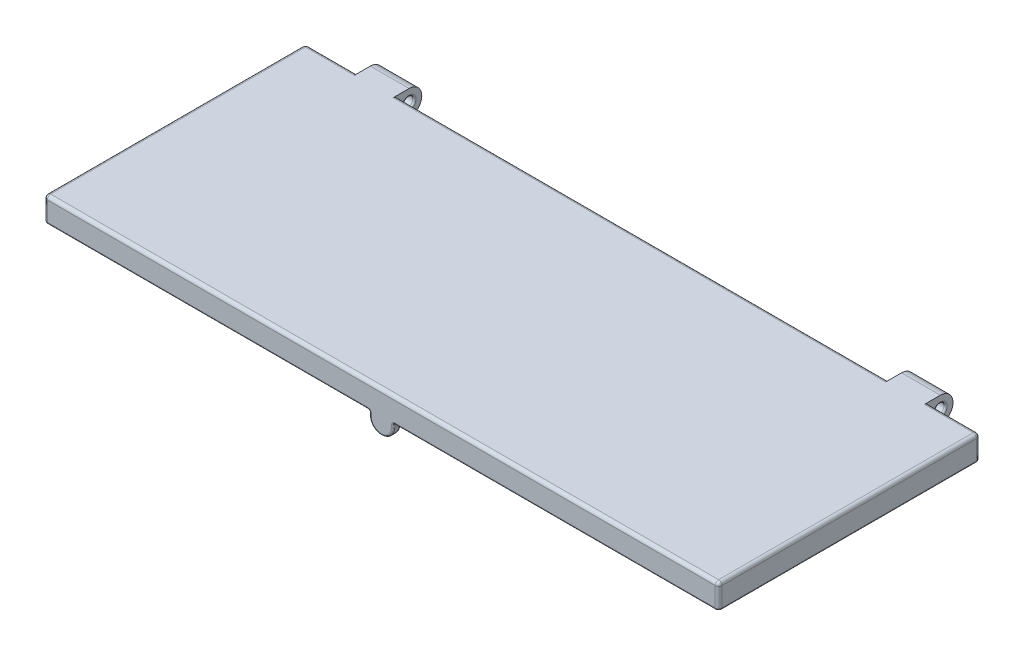
from build123d import *

# Parameters (mm, degrees)
SKETCH_1_W          = 160
SKETCH_1_H          = 62
EXTRUDE_1_DEPTH     = 4
SKETCH_2_R          = 3
SKETCH_2_R_2        = 1.25
EXTRUDE_2_DEPTH     = 9.2
EXTRUDE_3_DEPTH     = 1.8
EXTRUDE_4_DEPTH     = 1.8
SKETCH_5_R          = 0.6
CUT_EXTRUDE_1_DEPTH = 0.4
FILLET_1_R          = 0.8
FILLET_2_R          = 0.4
FILLET_3_R          = 0.1


with BuildPart() as part:
    # 草图1 → 凸台-拉伸1 (new body)
    with BuildSketch(Plane(origin=(0, 0, 0), x_dir=(1, 0, 0), z_dir=(0, 1, 0))):
        with Locations((80, 31)):
            Rectangle(SKETCH_1_W, SKETCH_1_H)
    extrude(amount=EXTRUDE_1_DEPTH)

    # 草图2 → 凸台-拉伸2 (add)
    with BuildSketch(Plane.ZY.offset(-147.6)):
        with BuildLine():
            Line((-62, 1), (-62, 4))
            Line((-62, 4), (-65, 4))
            ThreePointArc((-65, 4), (-62.878679656, 3.121320344), (-62, 1))
        make_face()
        with Locations((-65, 1)):
            Circle(SKETCH_2_R)
        with Locations((-65, 1)):
            Circle(SKETCH_2_R_2, mode=Mode.SUBTRACT)
        with BuildLine():
            Line((-62, 0), (-62, 1))
            ThreePointArc((-62, 1), (-62.153950106, 0.051316702), (-62.6, -0.8))
            Line((-62.6, -0.8), (-62, 0))
        make_face()
    extrude_2 = extrude(amount=EXTRUDE_2_DEPTH)

    # 镜向1: 凸台-拉伸2 across plane
    add(extrude_2.mirror(Plane(origin=(80, 0, 0), x_dir=(0, 0, 1), z_dir=(1, 0, 0))))

    # 草图3 → 凸台-拉伸3 (add)
    with BuildSketch(Plane.XZ):
        Polygon((160, 0), (160, -62), (158.2, -62), (158.2, -1.8), (1.8, -1.8), (1.8, -62), (0, -62), (0, 0), align=None)
    extrude(amount=EXTRUDE_3_DEPTH)

    # 草图4 → 凸台-拉伸4 (add)
    with BuildSketch(Plane.XY):
        with BuildLine():
            Line((77.2, -2.8), (77.2, -1.8))
            Line((77.2, -1.8), (82.8, -1.8))
            Line((82.8, -1.8), (82.8, -2.8))
            ThreePointArc((82.8, -2.8), (80, -5.6), (77.2, -2.8))
        make_face()
    extrude(amount=-EXTRUDE_4_DEPTH)

    # 草图5 → 切除-拉伸1 (cut)
    with BuildSketch(Plane(origin=(0, 0, -1.8), x_dir=(-1, 0, 0), z_dir=(0, 0, -1))):
        with Locations((-80, -3)):
            Circle(SKETCH_5_R)
    extrude(amount=-CUT_EXTRUDE_1_DEPTH, mode=Mode.SUBTRACT)

    # 圆角1
    fillet_1_edges = [part.edges().sort_by_distance(p)[0] for p in [
        (160, 4, -31),
        (80, 4, -62),
        (153.8, 4, -62),
        (6.2, 4, -62),
        (0, 4, -31),
        (0, 1.1, -62),
        (160, 1.1, -62),
        (160, 1.1, 0),
        (0, 1.1, 0),
        (80, 4, 0),
    ]]
    fillet(fillet_1_edges, radius=FILLET_1_R)

    # 圆角2
    fillet_2_edges = [part.edges().sort_by_distance(p)[0] for p in [
        (80, 0, -62),
        (138.4, 1, -66.25),
        (147.6, 1, -66.25),
        (7.1, 0, -62),
        (12.4, 1, -66.25),
        (21.6, 1, -66.25),
        (152.9, 0, -62),
        (1.8, 0, -31.9),
        (1.8, -0.9, -62),
        (80, 0, -1.8),
        (1.8, -0.9, -1.8),
        (158.2, 0, -31.9),
        (158.2, -0.9, -1.8),
        (158.2, -0.9, -62),
        (1.8, -1.8, -31.9),
        (39.5, -1.8, -1.8),
        (158.2, -1.8, -31.9),
        (158.7, -1.8, -62),
        (39, -1.8, 0),
        (120.5, -1.8, -1.8),
        (77.2, -1.8, -0.9),
        (82.8, -1.8, -0.9),
        (80, -5.6, 0),
        (82.8, -2.3, 0),
        (77.2, -2.3, 0),
        (80, -5.6, -1.8),
        (77.2, -2.3, -1.8),
        (82.8, -2.3, -1.8),
        (121, -1.8, 0),
        (0, -1.8, -31),
        (1.3, -1.8, -62),
        (0.234314575, -1.8, -61.765685425),
        (0.234314575, -1.8, -0.234314575),
        (160, -1.8, -31),
        (159.765685425, -1.8, -61.765685425),
        (159.765685425, -1.8, -0.234314575),
    ]]
    fillet(fillet_2_edges, radius=FILLET_2_R)

    # 圆角3
    fillet_3_edges = [part.edges().sort_by_distance(p)[0] for p in [
        (80.6, -3, -1.4),
        (80.6, -3, -1.8),
    ]]
    fillet(fillet_3_edges, radius=FILLET_3_R)


solid = part.part
